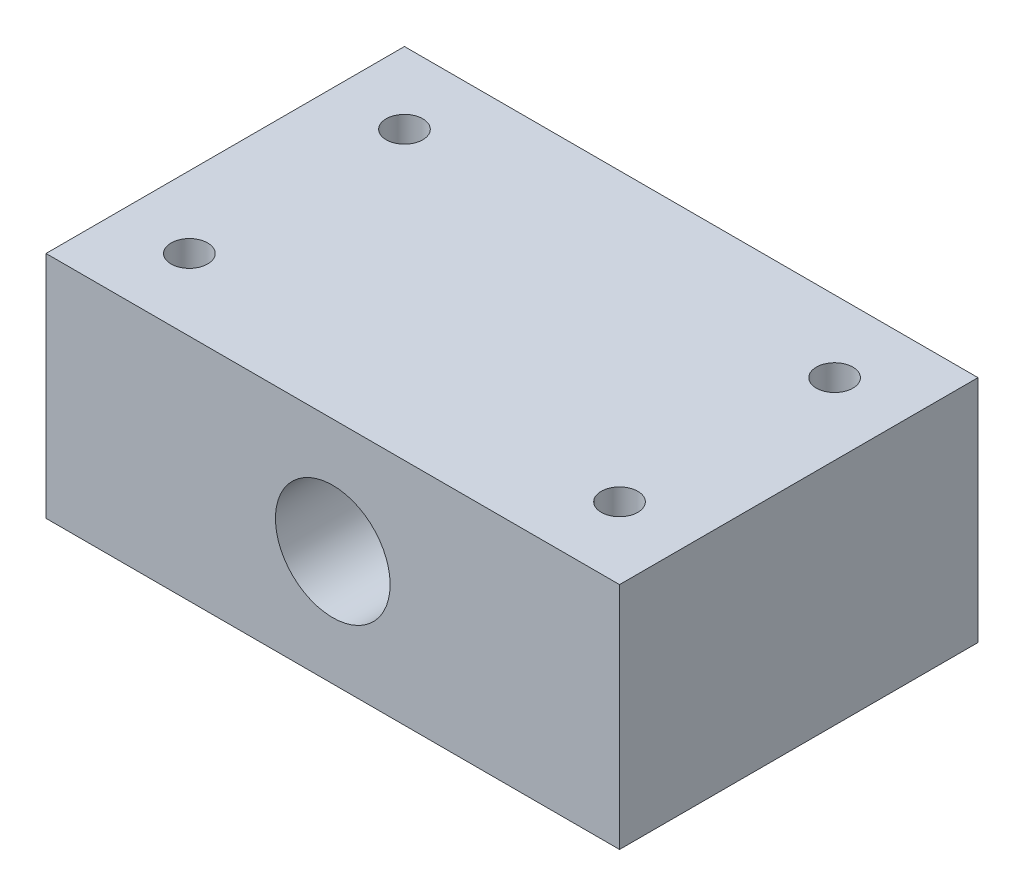
from build123d import *

# Parameters (mm, degrees)
SKETCH1_W           = 80
SKETCH1_H           = 50
SKETCH1_R           = 2.55
BOSS_EXTRUDE1_DEPTH = 32
SKETCH2_R           = 8
CUT_EXTRUDE1_DEPTH  = 50


with BuildPart() as part:
    # Sketch1 → Boss-Extrude1 (new body)
    with BuildSketch(Plane(origin=(0, 0, 0), x_dir=(1, 0, 0), z_dir=(0, 1, 0))):
        Rectangle(SKETCH1_W, SKETCH1_H)
        with Locations((-30, 15)):
            Circle(SKETCH1_R, mode=Mode.SUBTRACT)
        with Locations((30, 15)):
            Circle(SKETCH1_R, mode=Mode.SUBTRACT)
        with Locations((30, -15)):
            Circle(SKETCH1_R, mode=Mode.SUBTRACT)
        with Locations((-30, -15)):
            Circle(SKETCH1_R, mode=Mode.SUBTRACT)
    extrude(amount=BOSS_EXTRUDE1_DEPTH)

    # Sketch2 → Cut-Extrude1 (cut)
    with BuildSketch(Plane.XY.offset(25)):
        with Locations((0, 16)):
            Circle(SKETCH2_R)
    extrude(amount=-CUT_EXTRUDE1_DEPTH, mode=Mode.SUBTRACT)


solid = part.part
